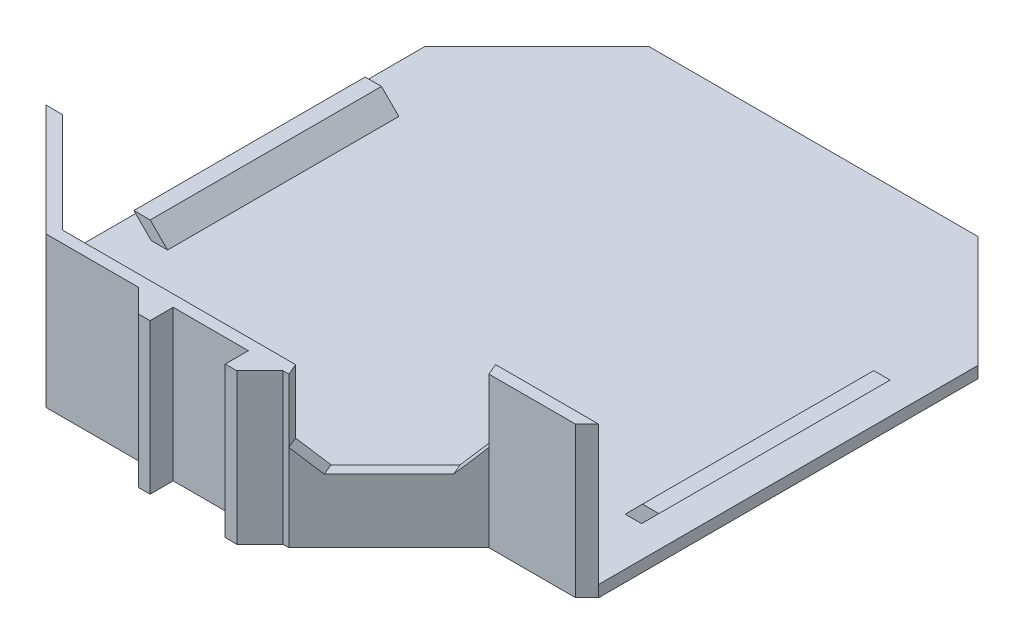
from build123d import *

# Parameters (mm, degrees)
BOSS_EXTRUDE1_DEPTH      = 2.54
CUT_EXTRUDE1_DEPTH       = 3.54
BOSS_EXTRUDE2_DEPTH      = 25.4
BOSS_EXTRUDE2_DEPTH_BACK = 25.4
BOSS_EXTRUDE3_DEPTH      = 30.48
CUT_EXTRUDE2_DEPTH       = 19.05
CHAMFER2_SIZE            = 5.08
BOSS_EXTRUDE4_DEPTH      = 33.02


with BuildPart() as part:
    # Sketch1 → Boss-Extrude1 (new body)
    with BuildSketch(Plane(origin=(0, 0, 0), x_dir=(1, 0, 0), z_dir=(0, 1, 0))):
        Polygon((-36.195, 66.167), (36.195, 66.167), (60.706, 41.656), (60.706, -41.656), (36.195, -66.167), (-36.195, -66.167), (-60.706, -41.656), (-60.706, 41.656), align=None)
    extrude(amount=BOSS_EXTRUDE1_DEPTH)

    # Sketch5 → Cut-Extrude1 (cut, through all)
    with BuildSketch(Plane(origin=(0, 2.54, 0), x_dir=(1, 0, 0), z_dir=(0, 1, 0))):
        Polygon((58.166, -44.196), (36.195, -66.167), (17.145, -66.167), (39.116, -44.196), align=None)
    extrude(amount=-CUT_EXTRUDE1_DEPTH, mode=Mode.SUBTRACT)

    # Sketch3 → Boss-Extrude2 (add, two sides)
    with BuildSketch(Plane.XY) as boss_extrude2_sk:
        Polygon((-53.848, 2.54), (-57.658, 6.35), (-54.065897552, 6.35), (-50.255897552, 2.54), align=None)
        Polygon((54.065897552, 6.35), (50.255897552, 2.54), (53.848, 2.54), (57.658, 6.35), align=None)
    extrude(amount=BOSS_EXTRUDE2_DEPTH)
    extrude(boss_extrude2_sk.sketch, amount=-BOSS_EXTRUDE2_DEPTH_BACK)

    # Sketch4 → Boss-Extrude3 (add)
    with BuildSketch(Plane(origin=(0, 2.54, 0), x_dir=(1, 0, 0), z_dir=(0, 1, 0))):
        Polygon((60.706, -41.656), (58.166, -41.656), (38.063897552, -41.656), (16.092897552, -63.627), (-35.142897552, -63.627), (-57.113897552, -41.656), (-60.706, -41.656), (-36.195, -66.167), (17.145, -66.167), (39.116, -44.196), (58.166, -44.196), align=None)
    extrude(amount=BOSS_EXTRUDE3_DEPTH)

    # Sketch6 → Cut-Extrude2 (cut)
    with BuildSketch(Plane(origin=(0, 33.02, 0), x_dir=(1, 0, 0), z_dir=(0, 1, 0))):
        Polygon((38.063897552, -41.656), (16.092897552, -63.627), (17.145, -66.167), (39.116, -44.196), align=None)
    extrude(amount=-CUT_EXTRUDE2_DEPTH, mode=Mode.SUBTRACT)

    # Chamfer2
    chamfer2_edges = [part.edges().sort_by_distance(p)[0] for p in [
        (16.618948776, 13.97, 64.897),
        (38.589948776, 13.97, 42.926),
    ]]
    chamfer(chamfer2_edges, length=CHAMFER2_SIZE)

    # Sketch7 → Boss-Extrude4 (add)
    with BuildSketch(Plane.XZ):
        Polygon((-8.255, 66.167), (-8.255, 71.247), (-10.795, 71.247), (-15.875, 66.167), align=None)
        Polygon((10.795, 71.247), (15.875, 66.167), (8.255, 66.167), (8.255, 71.247), align=None)
    extrude(amount=-BOSS_EXTRUDE4_DEPTH)


solid = part.part
